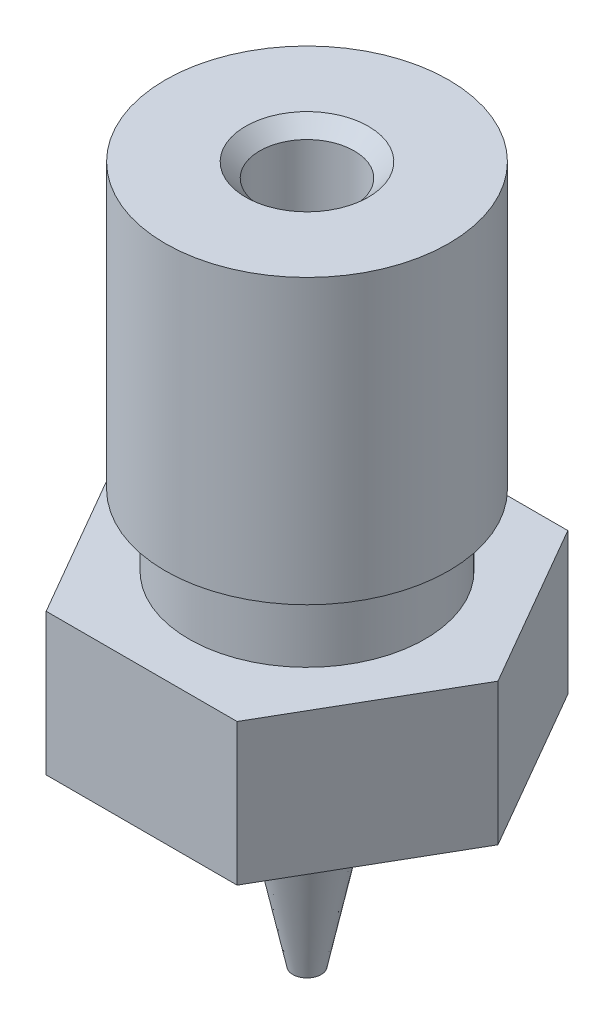
from build123d import *

# Parameters (mm, degrees)
BOSS_EXTRUDE1_DEPTH = 3


with BuildPart() as part:
    # Sketch1 → Revolve1 (revolve)
    with BuildSketch(Plane.XY):
        Polygon((0, 0), (0.5, 0), (1.900415076, 2), (3.5, 2), (3.5, 5), (2.5, 5), (2.5, 6.5), (3, 6.5), (3, 12.5), (0, 12.5), align=None)
    revolve(axis=Axis((0, -1.1291331, 0), (0, -1, 0)))

    # Sketch2 → Cut-Revolve1 (revolve, cut)
    with BuildSketch(Plane.XY):
        Polygon((0, 12.5), (1.3, 12.5), (1, 12.2), (1, 1.985640646), (0.2, 0.6), (0.2, 0), (0, 0), align=None)
    revolve(axis=Axis((0, 0, 0), (0, 1, 0)), mode=Mode.SUBTRACT)

    # Sketch3 → Boss-Extrude1 (add)
    with BuildSketch(Plane.XZ.offset(-2)):
        with BuildLine():
            ThreePointArc((-3.031088921, -1.749999986), (-3.5, 0), (-3.031088921, 1.749999986))
            Line((-3.031088921, 1.749999986), (-4.041451884, 0))
            Line((-4.041451884, 0), (-3.031088921, -1.749999986))
        make_face()
        with BuildLine():
            ThreePointArc((-3.031088921, 1.749999986), (-1.750000007, 3.031088909), (0, 3.5))
            Line((0, 3.5), (-2.020725942, 3.5))
            Line((-2.020725942, 3.5), (-3.031088921, 1.749999986))
        make_face()
        with BuildLine():
            ThreePointArc((0, 3.5), (1.750000007, 3.031088909), (3.031088922, 1.749999985))
            Line((3.031088922, 1.749999985), (2.020725942, 3.5))
            Line((2.020725942, 3.5), (0, 3.5))
        make_face()
        with BuildLine():
            Line((2.020725942, -3.5), (3.031088915, -1.749999996))
            ThreePointArc((3.031088915, -1.749999996), (1.750000009, -3.031088908), (1.6e-08, -3.5))
            Line((1.6e-08, -3.5), (2.020725942, -3.5))
        make_face()
        with BuildLine():
            Line((-2.020725942, -3.5), (1.6e-08, -3.5))
            ThreePointArc((1.6e-08, -3.5), (-1.75, -3.031088913), (-3.031088921, -1.749999986))
            Line((-3.031088921, -1.749999986), (-2.020725942, -3.5))
        make_face()
        with BuildLine():
            Line((3.031088915, -1.749999996), (4.041451884, 0))
            Line((4.041451884, 0), (3.031088922, 1.749999985))
            ThreePointArc((3.031088922, 1.749999985), (3.380740394, 0.90586665), (3.5, 0))
            ThreePointArc((3.5, 0), (3.380740393, -0.905866656), (3.031088915, -1.749999996))
        make_face()
    extrude(amount=-BOSS_EXTRUDE1_DEPTH)

    # Sketch4 → Revolve2 (revolve)
    with BuildSketch(Plane.XY):
        Polygon((0, 0), (0, -2.25), (0.3, -2.25), (0.885114146, 0.55), (1.3, 0.55), (1.3, 2), (1.008290377, 2), (1, 1.985640646), (0.2, 0.6), (0.2, 0), align=None)
    revolve(axis=Axis((0, 2, 0), (0, -1, 0)))


solid = part.part
